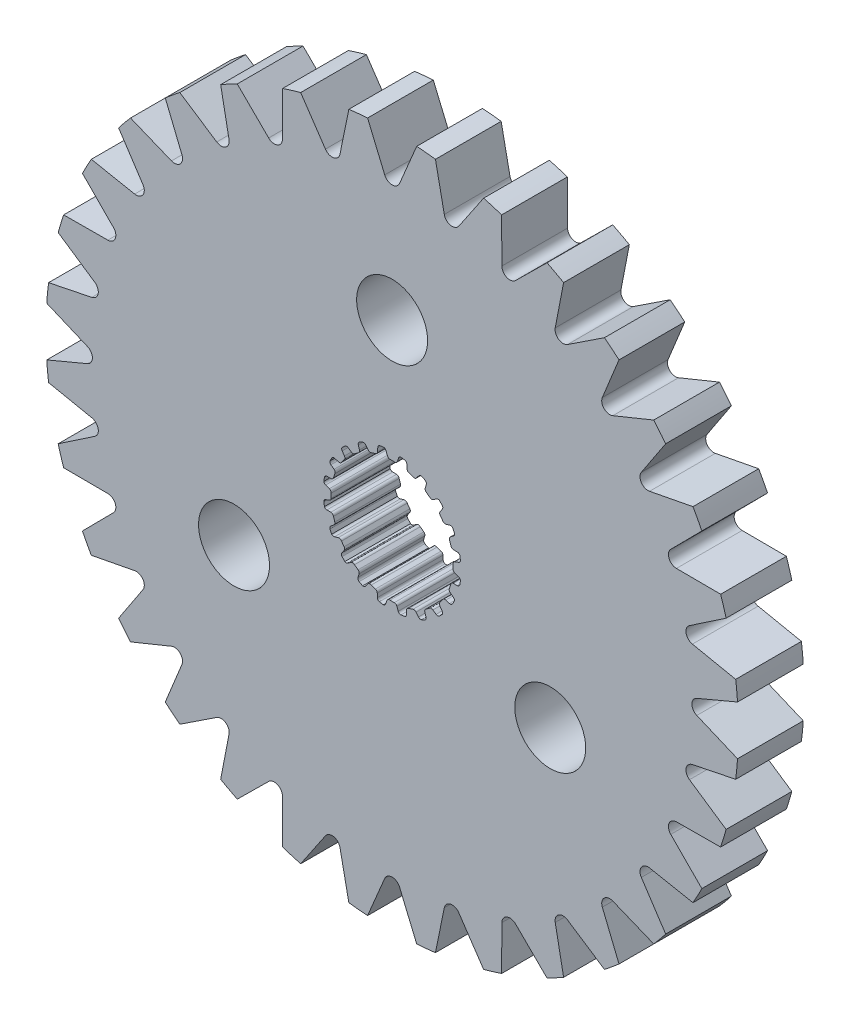
from build123d import *

# Parameters (mm, degrees)
SKETCH1_R           = 16.860601328
BOSS_EXTRUDE1_DEPTH = 3.2004
CUT_EXTRUDE1_DEPTH  = 3.2004
SKETCH5_R           = 1.7272
CUT_EXTRUDE2_DEPTH  = 3.2004


with BuildPart() as part:
    # Sketch1 → Boss-Extrude1 (new body)
    with BuildSketch(Plane.XY):
        Circle(SKETCH1_R)
        with BuildLine():
            Line((-0.106949245, 2.969874934), (0.106949245, 2.969874934))
            ThreePointArc((0.106949245, 2.969874934), (0.196343213, 2.986924176), (0.253739238, 3.057547504))
            Line((0.253739238, 3.057547504), (0.315888147, 3.237526941))
            ThreePointArc((0.315888147, 3.237526941), (0.359032156, 3.298322911), (0.4281449, 3.326269005))
            Line((0.4281449, 3.326269005), (0.620027588, 3.2937547))
            ThreePointArc((0.620027588, 3.2937547), (0.689621142, 3.24802576), (0.718272212, 3.169836791))
            Line((0.718272212, 3.169836791), (0.724389167, 2.979527391))
            ThreePointArc((0.724389167, 2.979527391), (0.750934762, 2.9040661), (0.816027049, 2.857568043))
            Line((0.816027049, 2.857568043), (1.019456602, 2.791469774))
            ThreePointArc((1.019456602, 2.791469774), (1.109743823, 2.780060312), (1.186154496, 2.829490741))
            Line((1.186154496, 2.829490741), (1.300878326, 2.981456288))
            ThreePointArc((1.300878326, 2.981456288), (1.360697704, 3.02594446), (1.435063648, 3.031165762))
            Line((1.435063648, 3.031165762), (1.607507455, 2.940947809))
            ThreePointArc((1.607507455, 2.940947809), (1.659563839, 2.875951412), (1.662650905, 2.792735615))
            Line((1.662650905, 2.792735615), (1.609659636, 2.609850378))
            ThreePointArc((1.609659636, 2.609850378), (1.611587176, 2.529879385), (1.659124931, 2.465542482))
            Line((1.659124931, 2.465542482), (1.832172444, 2.339816104))
            ThreePointArc((1.832172444, 2.339816104), (1.914514976, 2.301064775), (2.002460687, 2.32446371))
            Line((2.002460687, 2.32446371), (2.158529469, 2.433539921))
            ThreePointArc((2.158529469, 2.433539921), (2.229168681, 2.457365482), (2.301508367, 2.439350895))
            Line((2.301508367, 2.439350895), (2.437633293, 2.300260456))
            ThreePointArc((2.437633293, 2.300260456), (2.467056864, 2.222358901), (2.444277744, 2.14226202))
            Line((2.444277744, 2.14226202), (2.337365406, 1.984703026))
            ThreePointArc((2.337365406, 1.984703026), (2.314486209, 1.908050449), (2.339816104, 1.832172444))
            Line((2.339816104, 1.832172444), (2.465542482, 1.659124931))
            ThreePointArc((2.465542482, 1.659124931), (2.531880064, 1.596824985), (2.622752074, 1.591901975))
            Line((2.622752074, 1.591901975), (2.804888709, 1.64741171))
            ThreePointArc((2.804888709, 1.64741171), (2.879433095, 1.648242449), (2.942665411, 1.608755366))
            Line((2.942665411, 1.608755366), (3.0291466, 1.434407582))
            ThreePointArc((3.0291466, 1.434407582), (3.033057175, 1.351226417), (2.986641646, 1.282088892))
            Line((2.986641646, 1.282088892), (2.836273564, 1.165279113))
            ThreePointArc((2.836273564, 1.165279113), (2.790827206, 1.099448241), (2.791469774, 1.019456602))
            Line((2.791469774, 1.019456602), (2.857568043, 0.816027049))
            ThreePointArc((2.857568043, 0.816027049), (2.901407091, 0.736276839), (2.986310214, 0.703513784))
            Line((2.986310214, 0.703513784), (3.1766859, 0.700023363))
            ThreePointArc((3.1766859, 0.700023363), (3.247838536, 0.677777961), (3.295773863, 0.620683653))
            Line((3.295773863, 0.620683653), (3.324145932, 0.4281449))
            ThreePointArc((3.324145932, 0.4281449), (3.302160717, 0.347826477), (3.236652255, 0.29641597))
            Line((3.236652255, 0.29641597), (3.057547504, 0.231789562))
            ThreePointArc((3.057547504, 0.231789562), (2.993982591, 0.183224379), (2.969874934, 0.106949245))
            Line((2.969874934, 0.106949245), (2.969874934, -0.106949245))
            ThreePointArc((2.969874934, -0.106949245), (2.986924176, -0.196343213), (3.057547504, -0.253739238))
            Line((3.057547504, -0.253739238), (3.237526941, -0.315888147))
            ThreePointArc((3.237526941, -0.315888147), (3.298322911, -0.359032156), (3.326269005, -0.4281449))
            Line((3.326269005, -0.4281449), (3.2937547, -0.620027588))
            ThreePointArc((3.2937547, -0.620027588), (3.24802576, -0.689621142), (3.169836791, -0.718272212))
            Line((3.169836791, -0.718272212), (2.979527391, -0.724389167))
            ThreePointArc((2.979527391, -0.724389167), (2.9040661, -0.750934762), (2.857568043, -0.816027049))
            Line((2.857568043, -0.816027049), (2.791469774, -1.019456602))
            ThreePointArc((2.791469774, -1.019456602), (2.780060312, -1.109743823), (2.829490741, -1.186154496))
            Line((2.829490741, -1.186154496), (2.981456288, -1.300878326))
            ThreePointArc((2.981456288, -1.300878326), (3.02594446, -1.360697704), (3.031165762, -1.435063648))
            Line((3.031165762, -1.435063648), (2.940947809, -1.607507455))
            ThreePointArc((2.940947809, -1.607507455), (2.875951412, -1.659563839), (2.792735615, -1.662650905))
            Line((2.792735615, -1.662650905), (2.609850378, -1.609659636))
            ThreePointArc((2.609850378, -1.609659636), (2.529879385, -1.611587176), (2.465542482, -1.659124931))
            Line((2.465542482, -1.659124931), (2.339816104, -1.832172444))
            ThreePointArc((2.339816104, -1.832172444), (2.301064775, -1.914514976), (2.32446371, -2.002460687))
            Line((2.32446371, -2.002460687), (2.433539921, -2.158529469))
            ThreePointArc((2.433539921, -2.158529469), (2.457365482, -2.229168681), (2.439350895, -2.301508367))
            Line((2.439350895, -2.301508367), (2.300260456, -2.437633293))
            ThreePointArc((2.300260456, -2.437633293), (2.222358901, -2.467056864), (2.14226202, -2.444277744))
            Line((2.14226202, -2.444277744), (1.984703026, -2.337365406))
            ThreePointArc((1.984703026, -2.337365406), (1.908050449, -2.314486209), (1.832172444, -2.339816104))
            Line((1.832172444, -2.339816104), (1.659124931, -2.465542482))
            ThreePointArc((1.659124931, -2.465542482), (1.596824985, -2.531880064), (1.591901975, -2.622752074))
            Line((1.591901975, -2.622752074), (1.64741171, -2.804888709))
            ThreePointArc((1.64741171, -2.804888709), (1.648242449, -2.879433095), (1.608755366, -2.942665411))
            Line((1.608755366, -2.942665411), (1.434407582, -3.0291466))
            ThreePointArc((1.434407582, -3.0291466), (1.351226417, -3.033057175), (1.282088892, -2.986641646))
            Line((1.282088892, -2.986641646), (1.165279113, -2.836273564))
            ThreePointArc((1.165279113, -2.836273564), (1.099448241, -2.790827206), (1.019456602, -2.791469774))
            Line((1.019456602, -2.791469774), (0.816027049, -2.857568043))
            ThreePointArc((0.816027049, -2.857568043), (0.736276839, -2.901407091), (0.703513784, -2.986310214))
            Line((0.703513784, -2.986310214), (0.700023363, -3.1766859))
            ThreePointArc((0.700023363, -3.1766859), (0.677777961, -3.247838536), (0.620683653, -3.295773863))
            Line((0.620683653, -3.295773863), (0.4281449, -3.324145932))
            ThreePointArc((0.4281449, -3.324145932), (0.347826477, -3.302160717), (0.29641597, -3.236652255))
            Line((0.29641597, -3.236652255), (0.231789562, -3.057547504))
            ThreePointArc((0.231789562, -3.057547504), (0.183224379, -2.993982591), (0.106949245, -2.969874934))
            Line((0.106949245, -2.969874934), (-0.106949245, -2.969874934))
            ThreePointArc((-0.106949245, -2.969874934), (-0.196343213, -2.986924176), (-0.253739238, -3.057547504))
            Line((-0.253739238, -3.057547504), (-0.315888147, -3.237526941))
            ThreePointArc((-0.315888147, -3.237526941), (-0.359032156, -3.298322911), (-0.4281449, -3.326269005))
            Line((-0.4281449, -3.326269005), (-0.620027588, -3.2937547))
            ThreePointArc((-0.620027588, -3.2937547), (-0.689621142, -3.24802576), (-0.718272212, -3.169836791))
            Line((-0.718272212, -3.169836791), (-0.724389167, -2.979527391))
            ThreePointArc((-0.724389167, -2.979527391), (-0.750934762, -2.9040661), (-0.816027049, -2.857568043))
            Line((-0.816027049, -2.857568043), (-1.019456602, -2.791469774))
            ThreePointArc((-1.019456602, -2.791469774), (-1.109743823, -2.780060312), (-1.186154496, -2.829490741))
            Line((-1.186154496, -2.829490741), (-1.300878326, -2.981456288))
            ThreePointArc((-1.300878326, -2.981456288), (-1.360697704, -3.02594446), (-1.435063648, -3.031165762))
            Line((-1.435063648, -3.031165762), (-1.607507455, -2.940947809))
            ThreePointArc((-1.607507455, -2.940947809), (-1.659563839, -2.875951412), (-1.662650905, -2.792735615))
            Line((-1.662650905, -2.792735615), (-1.609659636, -2.609850378))
            ThreePointArc((-1.609659636, -2.609850378), (-1.611587176, -2.529879385), (-1.659124931, -2.465542482))
            Line((-1.659124931, -2.465542482), (-1.832172444, -2.339816104))
            ThreePointArc((-1.832172444, -2.339816104), (-1.914514976, -2.301064775), (-2.002460687, -2.32446371))
            Line((-2.002460687, -2.32446371), (-2.158529469, -2.433539921))
            ThreePointArc((-2.158529469, -2.433539921), (-2.229168681, -2.457365482), (-2.301508367, -2.439350895))
            Line((-2.301508367, -2.439350895), (-2.437633293, -2.300260456))
            ThreePointArc((-2.437633293, -2.300260456), (-2.467056864, -2.222358901), (-2.444277744, -2.14226202))
            Line((-2.444277744, -2.14226202), (-2.337365406, -1.984703026))
            ThreePointArc((-2.337365406, -1.984703026), (-2.314486209, -1.908050449), (-2.339816104, -1.832172444))
            Line((-2.339816104, -1.832172444), (-2.465542482, -1.659124931))
            ThreePointArc((-2.465542482, -1.659124931), (-2.531880064, -1.596824985), (-2.622752074, -1.591901975))
            Line((-2.622752074, -1.591901975), (-2.804888709, -1.64741171))
            ThreePointArc((-2.804888709, -1.64741171), (-2.879433095, -1.648242449), (-2.942665411, -1.608755366))
            Line((-2.942665411, -1.608755366), (-3.0291466, -1.434407582))
            ThreePointArc((-3.0291466, -1.434407582), (-3.033057175, -1.351226417), (-2.986641646, -1.282088892))
            Line((-2.986641646, -1.282088892), (-2.836273564, -1.165279113))
            ThreePointArc((-2.836273564, -1.165279113), (-2.790827206, -1.099448241), (-2.791469774, -1.019456602))
            Line((-2.791469774, -1.019456602), (-2.857568043, -0.816027049))
            ThreePointArc((-2.857568043, -0.816027049), (-2.901407091, -0.736276839), (-2.986310214, -0.703513784))
            Line((-2.986310214, -0.703513784), (-3.1766859, -0.700023363))
            ThreePointArc((-3.1766859, -0.700023363), (-3.247838536, -0.677777961), (-3.295773863, -0.620683653))
            Line((-3.295773863, -0.620683653), (-3.324145932, -0.4281449))
            ThreePointArc((-3.324145932, -0.4281449), (-3.302160717, -0.347826477), (-3.236652255, -0.29641597))
            Line((-3.236652255, -0.29641597), (-3.057547504, -0.231789562))
            ThreePointArc((-3.057547504, -0.231789562), (-2.993982591, -0.183224379), (-2.969874934, -0.106949245))
            Line((-2.969874934, -0.106949245), (-2.969874934, 0.106949245))
            ThreePointArc((-2.969874934, 0.106949245), (-2.986924176, 0.196343213), (-3.057547504, 0.253739238))
            Line((-3.057547504, 0.253739238), (-3.237526941, 0.315888147))
            ThreePointArc((-3.237526941, 0.315888147), (-3.298322911, 0.359032156), (-3.326269005, 0.4281449))
            Line((-3.326269005, 0.4281449), (-3.2937547, 0.620027588))
            ThreePointArc((-3.2937547, 0.620027588), (-3.24802576, 0.689621142), (-3.169836791, 0.718272212))
            Line((-3.169836791, 0.718272212), (-2.979527391, 0.724389167))
            ThreePointArc((-2.979527391, 0.724389167), (-2.9040661, 0.750934762), (-2.857568043, 0.816027049))
            Line((-2.857568043, 0.816027049), (-2.791469774, 1.019456602))
            ThreePointArc((-2.791469774, 1.019456602), (-2.780060312, 1.109743823), (-2.829490741, 1.186154496))
            Line((-2.829490741, 1.186154496), (-2.981456288, 1.300878326))
            ThreePointArc((-2.981456288, 1.300878326), (-3.02594446, 1.360697704), (-3.031165762, 1.435063648))
            Line((-3.031165762, 1.435063648), (-2.940947809, 1.607507455))
            ThreePointArc((-2.940947809, 1.607507455), (-2.875951412, 1.659563839), (-2.792735615, 1.662650905))
            Line((-2.792735615, 1.662650905), (-2.609850378, 1.609659636))
            ThreePointArc((-2.609850378, 1.609659636), (-2.529879385, 1.611587176), (-2.465542482, 1.659124931))
            Line((-2.465542482, 1.659124931), (-2.339816104, 1.832172444))
            ThreePointArc((-2.339816104, 1.832172444), (-2.301064775, 1.914514976), (-2.32446371, 2.002460687))
            Line((-2.32446371, 2.002460687), (-2.433539921, 2.158529469))
            ThreePointArc((-2.433539921, 2.158529469), (-2.457365482, 2.229168681), (-2.439350895, 2.301508367))
            Line((-2.439350895, 2.301508367), (-2.300260456, 2.437633293))
            ThreePointArc((-2.300260456, 2.437633293), (-2.222358901, 2.467056864), (-2.14226202, 2.444277744))
            Line((-2.14226202, 2.444277744), (-1.984703026, 2.337365406))
            ThreePointArc((-1.984703026, 2.337365406), (-1.908050449, 2.314486209), (-1.832172444, 2.339816104))
            Line((-1.832172444, 2.339816104), (-1.659124931, 2.465542482))
            ThreePointArc((-1.659124931, 2.465542482), (-1.596824985, 2.531880064), (-1.591901975, 2.622752074))
            Line((-1.591901975, 2.622752074), (-1.64741171, 2.804888709))
            ThreePointArc((-1.64741171, 2.804888709), (-1.648242449, 2.879433095), (-1.608755366, 2.942665411))
            Line((-1.608755366, 2.942665411), (-1.434407582, 3.0291466))
            ThreePointArc((-1.434407582, 3.0291466), (-1.351226417, 3.033057175), (-1.282088892, 2.986641646))
            Line((-1.282088892, 2.986641646), (-1.165279113, 2.836273564))
            ThreePointArc((-1.165279113, 2.836273564), (-1.099448241, 2.790827206), (-1.019456602, 2.791469774))
            Line((-1.019456602, 2.791469774), (-0.816027049, 2.857568043))
            ThreePointArc((-0.816027049, 2.857568043), (-0.736276839, 2.901407091), (-0.703513784, 2.986310214))
            Line((-0.703513784, 2.986310214), (-0.700023363, 3.1766859))
            ThreePointArc((-0.700023363, 3.1766859), (-0.677777961, 3.247838536), (-0.620683653, 3.295773863))
            Line((-0.620683653, 3.295773863), (-0.4281449, 3.324145932))
            ThreePointArc((-0.4281449, 3.324145932), (-0.347826477, 3.302160717), (-0.29641597, 3.236652255))
            Line((-0.29641597, 3.236652255), (-0.231789562, 3.057547504))
            ThreePointArc((-0.231789562, 3.057547504), (-0.183224379, 2.993982591), (-0.106949245, 2.969874934))
        make_face(mode=Mode.SUBTRACT)
    extrude(amount=BOSS_EXTRUDE1_DEPTH)

    # Sketch2 → Cut-Extrude1 (cut)
    with BuildSketch(Plane.XY.offset(3.2004)):
        with BuildLine():
            Line((-1.195753421, 16.818146476), (-0.361266579, 14.83454632))
            ThreePointArc((-0.361266579, 14.83454632), (0, 14.594594775), (0.361266579, 14.83454632))
            Line((0.361266579, 14.83454632), (1.195753421, 16.818146476))
            ThreePointArc((1.195753421, 16.818146476), (0, 16.860601328), (-1.195753421, 16.818146476))
        make_face()
        with BuildLine():
            Line((4.453834966, 16.261710587), (3.248401362, 14.479025059))
            ThreePointArc((3.248401362, 14.479025059), (2.847264194, 14.314163729), (2.539751475, 14.619984285))
            Line((2.539751475, 14.619984285), (2.108280258, 16.728270427))
            ThreePointArc((2.108280258, 16.728270427), (3.289340142, 16.536629601), (4.453834966, 16.261710587))
        make_face()
        with BuildLine():
            Line((7.540758131, 15.080346281), (6.010701902, 13.567082984))
            ThreePointArc((6.010701902, 13.567082984), (5.585109623, 13.483647398), (5.343168305, 13.843584454))
            Line((5.343168305, 13.843584454), (5.331293908, 15.995536327))
            ThreePointArc((5.331293908, 15.995536327), (6.452272788, 15.577164472), (7.540758131, 15.080346281))
        make_face()
        with BuildLine():
            Line((10.33789419, 13.319452723), (8.542014538, 12.133765519))
            ThreePointArc((8.542014538, 12.133765519), (8.10832242, 12.134962059), (7.941250173, 12.535183435))
            Line((7.941250173, 12.535183435), (8.349428924, 14.648102736))
            ThreePointArc((8.349428924, 14.648102736), (9.367248208, 14.019077649), (10.33789419, 13.319452723))
        make_face()
        with BuildLine():
            Line((12.737750772, 11.046700068), (10.745062347, 10.23415425))
            ThreePointArc((10.745062347, 10.23415425), (10.319936934, 10.319936934), (10.23415425, 10.745062347))
            Line((10.23415425, 10.745062347), (11.046700068, 12.737750772))
            ThreePointArc((11.046700068, 12.737750772), (11.922245534, 11.922245534), (12.737750772, 11.046700068))
        make_face()
        with BuildLine():
            Line((14.648102736, 8.349428924), (12.535183435, 7.941250173))
            ThreePointArc((12.535183435, 7.941250173), (12.134962059, 8.10832242), (12.133765519, 8.542014538))
            Line((12.133765519, 8.542014538), (13.319452723, 10.33789419))
            ThreePointArc((13.319452723, 10.33789419), (14.019077649, 9.367248208), (14.648102736, 8.349428924))
        make_face()
        with BuildLine():
            Line((15.995536327, 5.331293908), (13.843584454, 5.343168305))
            ThreePointArc((13.843584454, 5.343168305), (13.483647398, 5.585109623), (13.567082984, 6.010701902))
            Line((13.567082984, 6.010701902), (15.080346281, 7.540758131))
            ThreePointArc((15.080346281, 7.540758131), (15.577164472, 6.452272788), (15.995536327, 5.331293908))
        make_face()
        with BuildLine():
            Line((16.728270427, 2.108280258), (14.619984285, 2.539751475))
            ThreePointArc((14.619984285, 2.539751475), (14.314163729, 2.847264194), (14.479025059, 3.248401362))
            Line((14.479025059, 3.248401362), (16.261710587, 4.453834966))
            ThreePointArc((16.261710587, 4.453834966), (16.536629601, 3.289340142), (16.728270427, 2.108280258))
        make_face()
        with BuildLine():
            Line((16.818146476, -1.195753421), (14.83454632, -0.361266579))
            ThreePointArc((14.83454632, -0.361266579), (14.594594775, 0), (14.83454632, 0.361266579))
            Line((14.83454632, 0.361266579), (16.818146476, 1.195753421))
            ThreePointArc((16.818146476, 1.195753421), (16.860601328, 0), (16.818146476, -1.195753421))
        make_face()
        with BuildLine():
            Line((16.261710587, -4.453834966), (14.479025059, -3.248401362))
            ThreePointArc((14.479025059, -3.248401362), (14.314163729, -2.847264194), (14.619984285, -2.539751475))
            Line((14.619984285, -2.539751475), (16.728270427, -2.108280258))
            ThreePointArc((16.728270427, -2.108280258), (16.536629601, -3.289340142), (16.261710587, -4.453834966))
        make_face()
        with BuildLine():
            Line((15.080346281, -7.540758131), (13.567082984, -6.010701902))
            ThreePointArc((13.567082984, -6.010701902), (13.483647398, -5.585109623), (13.843584454, -5.343168305))
            Line((13.843584454, -5.343168305), (15.995536327, -5.331293908))
            ThreePointArc((15.995536327, -5.331293908), (15.577164472, -6.452272788), (15.080346281, -7.540758131))
        make_face()
        with BuildLine():
            Line((13.319452723, -10.33789419), (12.133765519, -8.542014538))
            ThreePointArc((12.133765519, -8.542014538), (12.134962059, -8.10832242), (12.535183435, -7.941250173))
            Line((12.535183435, -7.941250173), (14.648102736, -8.349428924))
            ThreePointArc((14.648102736, -8.349428924), (14.019077649, -9.367248208), (13.319452723, -10.33789419))
        make_face()
        with BuildLine():
            Line((11.046700068, -12.737750772), (10.23415425, -10.745062347))
            ThreePointArc((10.23415425, -10.745062347), (10.319936934, -10.319936934), (10.745062347, -10.23415425))
            Line((10.745062347, -10.23415425), (12.737750772, -11.046700068))
            ThreePointArc((12.737750772, -11.046700068), (11.922245534, -11.922245534), (11.046700068, -12.737750772))
        make_face()
        with BuildLine():
            Line((8.349428924, -14.648102736), (7.941250173, -12.535183435))
            ThreePointArc((7.941250173, -12.535183435), (8.10832242, -12.134962059), (8.542014538, -12.133765519))
            Line((8.542014538, -12.133765519), (10.33789419, -13.319452723))
            ThreePointArc((10.33789419, -13.319452723), (9.367248208, -14.019077649), (8.349428924, -14.648102736))
        make_face()
        with BuildLine():
            Line((5.331293908, -15.995536327), (5.343168305, -13.843584454))
            ThreePointArc((5.343168305, -13.843584454), (5.585109623, -13.483647398), (6.010701902, -13.567082984))
            Line((6.010701902, -13.567082984), (7.540758131, -15.080346281))
            ThreePointArc((7.540758131, -15.080346281), (6.452272788, -15.577164472), (5.331293908, -15.995536327))
        make_face()
        with BuildLine():
            Line((2.108280258, -16.728270427), (2.539751475, -14.619984285))
            ThreePointArc((2.539751475, -14.619984285), (2.847264194, -14.314163729), (3.248401362, -14.479025059))
            Line((3.248401362, -14.479025059), (4.453834966, -16.261710587))
            ThreePointArc((4.453834966, -16.261710587), (3.289340142, -16.536629601), (2.108280258, -16.728270427))
        make_face()
        with BuildLine():
            Line((-1.195753421, -16.818146476), (-0.361266579, -14.83454632))
            ThreePointArc((-0.361266579, -14.83454632), (0, -14.594594775), (0.361266579, -14.83454632))
            Line((0.361266579, -14.83454632), (1.195753421, -16.818146476))
            ThreePointArc((1.195753421, -16.818146476), (0, -16.860601328), (-1.195753421, -16.818146476))
        make_face()
        with BuildLine():
            Line((-4.453834966, -16.261710587), (-3.248401362, -14.479025059))
            ThreePointArc((-3.248401362, -14.479025059), (-2.847264194, -14.314163729), (-2.539751475, -14.619984285))
            Line((-2.539751475, -14.619984285), (-2.108280258, -16.728270427))
            ThreePointArc((-2.108280258, -16.728270427), (-3.289340142, -16.536629601), (-4.453834966, -16.261710587))
        make_face()
        with BuildLine():
            Line((-7.540758131, -15.080346281), (-6.010701902, -13.567082984))
            ThreePointArc((-6.010701902, -13.567082984), (-5.585109623, -13.483647398), (-5.343168305, -13.843584454))
            Line((-5.343168305, -13.843584454), (-5.331293908, -15.995536327))
            ThreePointArc((-5.331293908, -15.995536327), (-6.452272788, -15.577164472), (-7.540758131, -15.080346281))
        make_face()
        with BuildLine():
            Line((-10.33789419, -13.319452723), (-8.542014538, -12.133765519))
            ThreePointArc((-8.542014538, -12.133765519), (-8.10832242, -12.134962059), (-7.941250173, -12.535183435))
            Line((-7.941250173, -12.535183435), (-8.349428924, -14.648102736))
            ThreePointArc((-8.349428924, -14.648102736), (-9.367248208, -14.019077649), (-10.33789419, -13.319452723))
        make_face()
        with BuildLine():
            Line((-12.737750772, -11.046700068), (-10.745062347, -10.23415425))
            ThreePointArc((-10.745062347, -10.23415425), (-10.319936934, -10.319936934), (-10.23415425, -10.745062347))
            Line((-10.23415425, -10.745062347), (-11.046700068, -12.737750772))
            ThreePointArc((-11.046700068, -12.737750772), (-11.922245534, -11.922245534), (-12.737750772, -11.046700068))
        make_face()
        with BuildLine():
            Line((-14.648102736, -8.349428924), (-12.535183435, -7.941250173))
            ThreePointArc((-12.535183435, -7.941250173), (-12.134962059, -8.10832242), (-12.133765519, -8.542014538))
            Line((-12.133765519, -8.542014538), (-13.319452723, -10.33789419))
            ThreePointArc((-13.319452723, -10.33789419), (-14.019077649, -9.367248208), (-14.648102736, -8.349428924))
        make_face()
        with BuildLine():
            Line((-15.995536327, -5.331293908), (-13.843584454, -5.343168305))
            ThreePointArc((-13.843584454, -5.343168305), (-13.483647398, -5.585109623), (-13.567082984, -6.010701902))
            Line((-13.567082984, -6.010701902), (-15.080346281, -7.540758131))
            ThreePointArc((-15.080346281, -7.540758131), (-15.577164472, -6.452272788), (-15.995536327, -5.331293908))
        make_face()
        with BuildLine():
            Line((-16.728270427, -2.108280258), (-14.619984285, -2.539751475))
            ThreePointArc((-14.619984285, -2.539751475), (-14.314163729, -2.847264194), (-14.479025059, -3.248401362))
            Line((-14.479025059, -3.248401362), (-16.261710587, -4.453834966))
            ThreePointArc((-16.261710587, -4.453834966), (-16.536629601, -3.289340142), (-16.728270427, -2.108280258))
        make_face()
        with BuildLine():
            Line((-16.818146476, 1.195753421), (-14.83454632, 0.361266579))
            ThreePointArc((-14.83454632, 0.361266579), (-14.594594775, 0), (-14.83454632, -0.361266579))
            Line((-14.83454632, -0.361266579), (-16.818146476, -1.195753421))
            ThreePointArc((-16.818146476, -1.195753421), (-16.860601328, 0), (-16.818146476, 1.195753421))
        make_face()
        with BuildLine():
            Line((-16.261710587, 4.453834966), (-14.479025059, 3.248401362))
            ThreePointArc((-14.479025059, 3.248401362), (-14.314163729, 2.847264194), (-14.619984285, 2.539751475))
            Line((-14.619984285, 2.539751475), (-16.728270427, 2.108280258))
            ThreePointArc((-16.728270427, 2.108280258), (-16.536629601, 3.289340142), (-16.261710587, 4.453834966))
        make_face()
        with BuildLine():
            Line((-15.080346281, 7.540758131), (-13.567082984, 6.010701902))
            ThreePointArc((-13.567082984, 6.010701902), (-13.483647398, 5.585109623), (-13.843584454, 5.343168305))
            Line((-13.843584454, 5.343168305), (-15.995536327, 5.331293908))
            ThreePointArc((-15.995536327, 5.331293908), (-15.577164472, 6.452272788), (-15.080346281, 7.540758131))
        make_face()
        with BuildLine():
            Line((-13.319452723, 10.33789419), (-12.133765519, 8.542014538))
            ThreePointArc((-12.133765519, 8.542014538), (-12.134962059, 8.10832242), (-12.535183435, 7.941250173))
            Line((-12.535183435, 7.941250173), (-14.648102736, 8.349428924))
            ThreePointArc((-14.648102736, 8.349428924), (-14.019077649, 9.367248208), (-13.319452723, 10.33789419))
        make_face()
        with BuildLine():
            Line((-11.046700068, 12.737750772), (-10.23415425, 10.745062347))
            ThreePointArc((-10.23415425, 10.745062347), (-10.319936934, 10.319936934), (-10.745062347, 10.23415425))
            Line((-10.745062347, 10.23415425), (-12.737750772, 11.046700068))
            ThreePointArc((-12.737750772, 11.046700068), (-11.922245534, 11.922245534), (-11.046700068, 12.737750772))
        make_face()
        with BuildLine():
            Line((-8.349428924, 14.648102736), (-7.941250173, 12.535183435))
            ThreePointArc((-7.941250173, 12.535183435), (-8.10832242, 12.134962059), (-8.542014538, 12.133765519))
            Line((-8.542014538, 12.133765519), (-10.33789419, 13.319452723))
            ThreePointArc((-10.33789419, 13.319452723), (-9.367248208, 14.019077649), (-8.349428924, 14.648102736))
        make_face()
        with BuildLine():
            Line((-5.331293908, 15.995536327), (-5.343168305, 13.843584454))
            ThreePointArc((-5.343168305, 13.843584454), (-5.585109623, 13.483647398), (-6.010701902, 13.567082984))
            Line((-6.010701902, 13.567082984), (-7.540758131, 15.080346281))
            ThreePointArc((-7.540758131, 15.080346281), (-6.452272788, 15.577164472), (-5.331293908, 15.995536327))
        make_face()
        with BuildLine():
            Line((-2.108280258, 16.728270427), (-2.539751475, 14.619984285))
            ThreePointArc((-2.539751475, 14.619984285), (-2.847264194, 14.314163729), (-3.248401362, 14.479025059))
            Line((-3.248401362, 14.479025059), (-4.453834966, 16.261710587))
            ThreePointArc((-4.453834966, 16.261710587), (-3.289340142, 16.536629601), (-2.108280258, 16.728270427))
        make_face()
    extrude(amount=-CUT_EXTRUDE1_DEPTH, mode=Mode.SUBTRACT)

    # Sketch5 → Cut-Extrude2 (cut)
    with BuildSketch(Plane.XY.offset(3.2004)):
        with Locations((0, 8.89)):
            Circle(SKETCH5_R)
        with Locations((7.69896584, -4.445)):
            Circle(SKETCH5_R)
        with Locations((-7.69896584, -4.445)):
            Circle(SKETCH5_R)
    extrude(amount=-CUT_EXTRUDE2_DEPTH, mode=Mode.SUBTRACT)


solid = part.part
